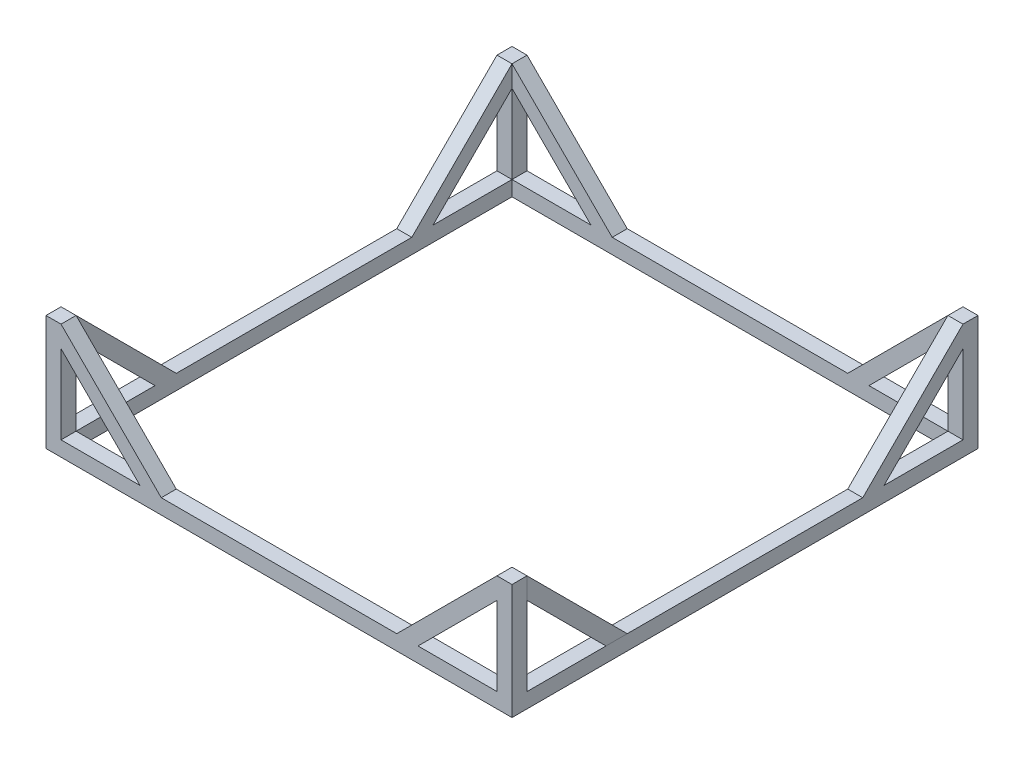
from build123d import *

# Parameters (mm, degrees)
SKETCH1_W            = 930
SKETCH1_H            = 930
SKETCH1_W_2          = 870
SKETCH1_H_2          = 870
BOSS_EXTRUDE1_DEPTH  = 30
SKETCH2_W            = 30
SKETCH2_H            = 30
BOSS_EXTRUDE2_DEPTH  = 200
BOSS_EXTRUDE3_DEPTH  = 30
BOSS_EXTRUDE4_DEPTH  = 30
BOSS_EXTRUDE5_DEPTH  = 30
BOSS_EXTRUDE6_DEPTH  = 30
BOSS_EXTRUDE7_DEPTH  = 30
BOSS_EXTRUDE8_DEPTH  = 30
BOSS_EXTRUDE9_DEPTH  = 30
BOSS_EXTRUDE10_DEPTH = 30


with BuildPart() as part:
    # Sketch1 → Boss-Extrude1 (new body)
    with BuildSketch(Plane(origin=(0, 0, 0), x_dir=(1, 0, 0), z_dir=(0, 1, 0))):
        Rectangle(SKETCH1_W, SKETCH1_H)
        Rectangle(SKETCH1_W_2, SKETCH1_H_2, mode=Mode.SUBTRACT)
    extrude(amount=BOSS_EXTRUDE1_DEPTH)

    # Sketch2 → Boss-Extrude2 (add)
    with BuildSketch(Plane(origin=(0, 30, 0), x_dir=(1, 0, 0), z_dir=(0, 1, 0))):
        with Locations((-450, 450)):
            Rectangle(SKETCH2_W, SKETCH2_H)
        with Locations((450, 450)):
            Rectangle(SKETCH2_W, SKETCH2_H)
        with Locations((450, -450)):
            Rectangle(SKETCH2_W, SKETCH2_H)
        with Locations((-450, -450)):
            Rectangle(SKETCH2_W, SKETCH2_H)
    extrude(amount=BOSS_EXTRUDE2_DEPTH)

    # Sketch4 → Boss-Extrude3 (add)
    with BuildSketch(Plane.ZY.offset(465)):
        Polygon((435, 187.573593129), (277.426406871, 30), (235, 30), (435, 230), align=None)
    extrude(amount=-BOSS_EXTRUDE3_DEPTH)

    # Sketch5 → Boss-Extrude4 (add)
    with BuildSketch(Plane.ZY.offset(465)):
        Polygon((-435, 187.573593129), (-435, 230), (-235, 30), (-277.426406871, 30), align=None)
    extrude(amount=-BOSS_EXTRUDE4_DEPTH)

    # Sketch6 → Boss-Extrude5 (add)
    with BuildSketch(Plane(origin=(0, 0, -465), x_dir=(-1, 0, 0), z_dir=(0, 0, -1))):
        Polygon((435, 230), (235, 30), (277.426406871, 30), (435, 187.573593129), align=None)
    extrude(amount=-BOSS_EXTRUDE5_DEPTH)

    # Sketch7 → Boss-Extrude6 (add)
    with BuildSketch(Plane(origin=(0, 0, -465), x_dir=(-1, 0, 0), z_dir=(0, 0, -1))):
        Polygon((-435, 230), (-235, 30), (-277.426406871, 30), (-435, 187.573593129), align=None)
    extrude(amount=-BOSS_EXTRUDE6_DEPTH)

    # Sketch8 → Boss-Extrude7 (add)
    with BuildSketch(Plane.XY.offset(465)):
        Polygon((-435, 230), (-235, 30), (-277.426406871, 30), (-435, 187.573593129), align=None)
    extrude(amount=-BOSS_EXTRUDE7_DEPTH)

    # Sketch9 → Boss-Extrude8 (add)
    with BuildSketch(Plane.XY.offset(465)):
        Polygon((435, 230), (235, 30), (277.426406871, 30), (435, 187.573593129), align=None)
    extrude(amount=-BOSS_EXTRUDE8_DEPTH)

    # Sketch11 → Boss-Extrude10 (add)
    with BuildSketch(Plane(origin=(465, 0, 0), x_dir=(0, 0, -1), z_dir=(1, 0, 0))):
        Polygon((435, 230), (235, 30), (277.426406871, 30), (435, 187.573593129), align=None)
    extrude(amount=-BOSS_EXTRUDE10_DEPTH)


with BuildPart() as body_2:
    # Sketch10 → Boss-Extrude9 (new body)
    with BuildSketch(Plane(origin=(465, 0, 0), x_dir=(0, 0, -1), z_dir=(1, 0, 0))):
        Polygon((-435, 230), (-235, 30), (-277.426406871, 30), (-435, 187.573593129), align=None)
    extrude(amount=-BOSS_EXTRUDE9_DEPTH)


solid = Compound([part.part, body_2.part])
